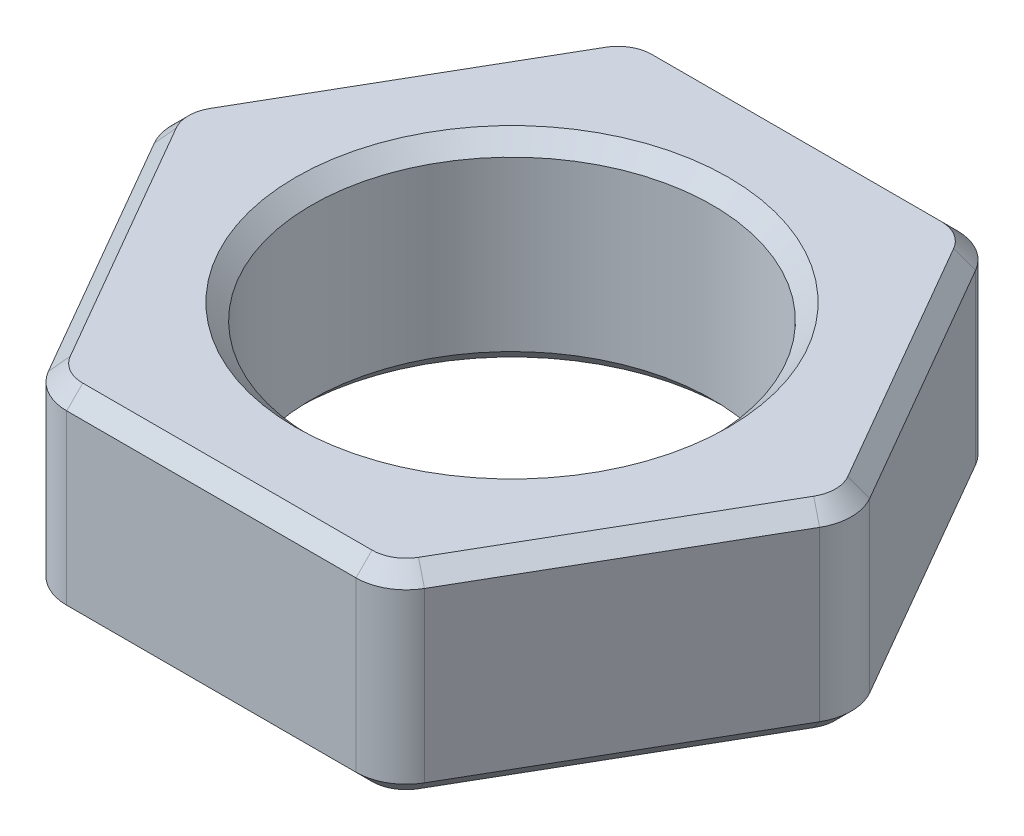
from build123d import *

# Parameters (mm, degrees)
SKETCH1_R           = 3.175
BOSS_EXTRUDE1_DEPTH = 1.5875
FILLET1_R           = 0.79375
CHAMFER1_SIZE       = 0.254


with BuildPart() as part:
    # Sketch1 → Boss-Extrude1 (new body, symmetric)
    with BuildSketch(Plane(origin=(0, 0, 0), x_dir=(1, 0, 0), z_dir=(0, 1, 0))):
        Polygon((2.749630657, 4.7625), (-2.749630657, 4.7625), (-5.499261314, 0), (-2.749630657, -4.7625), (2.749630657, -4.7625), (5.499261314, 0), align=None)
        Circle(SKETCH1_R, mode=Mode.SUBTRACT)
    extrude(amount=BOSS_EXTRUDE1_DEPTH, both=True)

    # Fillet1
    fillet1_edges = [part.edges().sort_by_distance(p)[0] for p in [
        (5.499261314, 0, 0),
        (2.749630657, 0, 4.7625),
        (-2.749630657, 0, 4.7625),
        (-5.499261314, 0, 0),
        (-2.749630657, 0, -4.7625),
        (2.749630657, 0, -4.7625),
    ]]
    fillet(fillet1_edges, radius=FILLET1_R)

    # Chamfer1
    chamfer1_edges = [part.edges().sort_by_distance(p)[0] for p in [
        (-3.175, -1.5875, 0),
        (-3.175, 1.5875, 0),
        (-4.124445986, -1.5875, 2.38125),
        (-4.124445986, 1.5875, 2.38125),
        (4.124445986, -1.5875, -2.38125),
        (4.124445986, -1.5875, 2.38125),
        (0, -1.5875, 4.7625),
        (-4.124445986, -1.5875, -2.38125),
        (0, -1.5875, -4.7625),
        (2.688233881, -1.5875, 4.656157664),
        (-2.688233881, -1.5875, 4.656157664),
        (5.376467762, -1.5875, 0),
        (2.688233881, -1.5875, -4.656157664),
        (-2.688233881, -1.5875, -4.656157664),
        (-5.376467762, -1.5875, 0),
        (-4.124445986, 1.5875, -2.38125),
        (4.124445986, 1.5875, -2.38125),
        (0, 1.5875, -4.7625),
        (0, 1.5875, 4.7625),
        (4.124445986, 1.5875, 2.38125),
        (2.688233881, 1.5875, 4.656157664),
        (-2.688233881, 1.5875, 4.656157664),
        (5.376467762, 1.5875, 0),
        (2.688233881, 1.5875, -4.656157664),
        (-2.688233881, 1.5875, -4.656157664),
        (-5.376467762, 1.5875, 0),
    ]]
    chamfer(chamfer1_edges, length=CHAMFER1_SIZE)


solid = part.part
